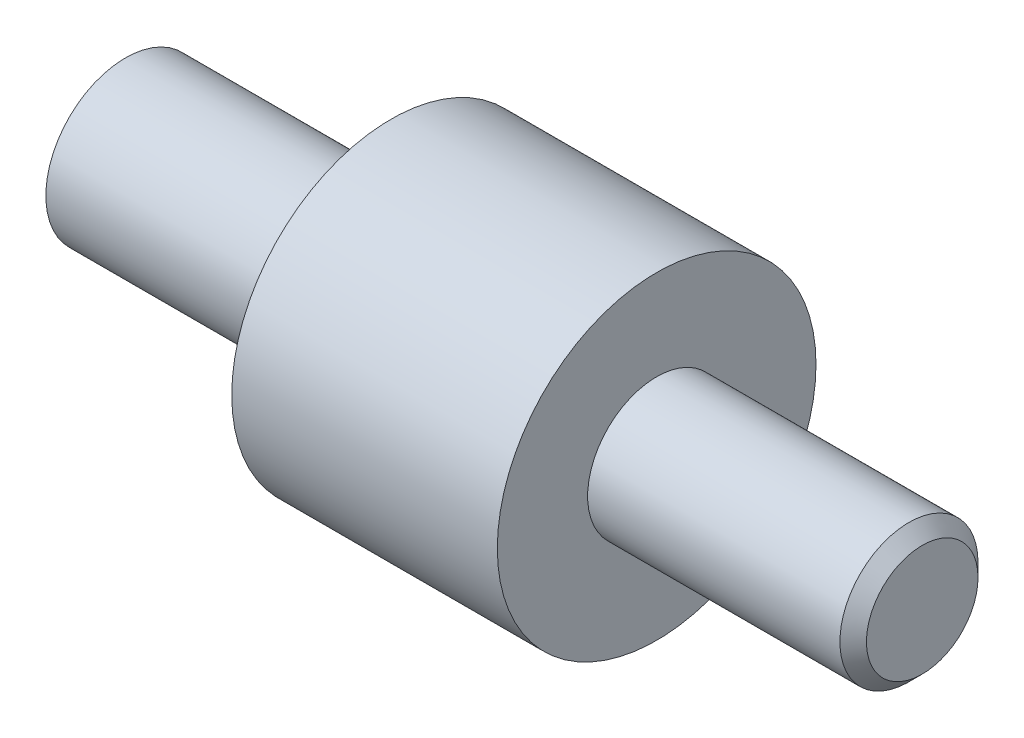
from build123d import *

# Parameters (mm, degrees)
CHANFREIN1_SIZE = 0.25


with BuildPart() as part:
    # Esquisse1 → Révolution1 (revolve)
    with BuildSketch(Plane.XY, mode=Mode.PRIVATE) as r_volution1_sk:
        Polygon((0, 0), (0, 1.5), (5, 1.5), (5, 3), (10, 3), (10, 1.3), (15, 1.3), (15, 0), align=None)
    revolve(r_volution1_sk.sketch.rotate(Axis((15, 0, 0), (-1, 0, 0)), 90), axis=Axis((15, 0, 0), (-1, 0, 0)))  # turned: the seam where the file's is

    # Chanfrein1
    chanfrein1_edges = [part.edges().sort_by_distance(p)[0] for p in [
        (15, 0, 1.3),
    ]]
    chamfer(chanfrein1_edges, length=CHANFREIN1_SIZE)


solid = part.part
